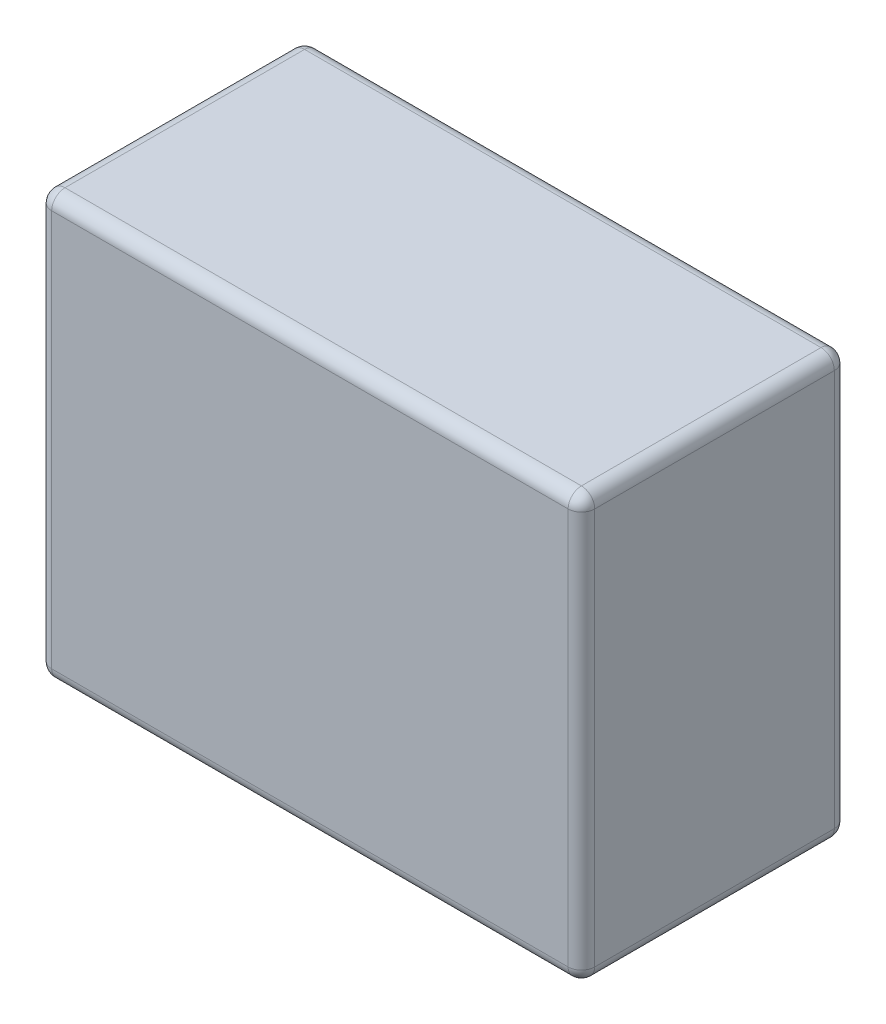
from build123d import *

# Parameters (mm, degrees)
SKETCH1_W           = 40.8
SKETCH1_H           = 20
BOSS_EXTRUDE1_DEPTH = 36.4
SKETCH2_W           = 40.8
SKETCH2_H           = 20
SKETCH2_W_2         = 37.24847256
SKETCH2_H_2         = 17
CUT_EXTRUDE1_DEPTH  = 4.6
SKETCH3_W           = 37.24847256
SKETCH3_H           = 17
SKETCH3_R           = 5
CUT_EXTRUDE2_DEPTH  = 3.9
SKETCH4_R           = 5
SKETCH4_R_2         = 3.5
CUT_EXTRUDE3_DEPTH  = 3
FILLET1_R           = 1
FILLET2_R           = 0.25


with BuildPart() as part:
    # Sketch1 → Boss-Extrude1 (new body)
    with BuildSketch(Plane(origin=(0, 0, 0), x_dir=(1, 0, 0), z_dir=(0, 1, 0))):
        Rectangle(SKETCH1_W, SKETCH1_H)
    extrude(amount=BOSS_EXTRUDE1_DEPTH)

    # Sketch2 → Cut-Extrude1 (cut)
    with BuildSketch(Plane(origin=(0, 0, 0), x_dir=(1, 0, 0), z_dir=(0, 1, 0))):
        Rectangle(SKETCH2_W, SKETCH2_H)
        Rectangle(SKETCH2_W_2, SKETCH2_H_2, mode=Mode.SUBTRACT)
    extrude(amount=CUT_EXTRUDE1_DEPTH, mode=Mode.SUBTRACT)

    # Sketch3 → Cut-Extrude2 (cut)
    with BuildSketch(Plane(origin=(0, 0, 0), x_dir=(1, 0, 0), z_dir=(0, 1, 0))):
        Rectangle(SKETCH3_W, SKETCH3_H)
        with Locations((9.31211814, 0)):
            Circle(SKETCH3_R, mode=Mode.SUBTRACT)
    extrude(amount=CUT_EXTRUDE2_DEPTH, mode=Mode.SUBTRACT)

    # Sketch4 → Cut-Extrude3 (cut)
    with BuildSketch(Plane(origin=(0, 0, 0), x_dir=(1, 0, 0), z_dir=(0, 1, 0))):
        with Locations((9.31211814, 0)):
            Circle(SKETCH4_R)
        with Locations((9.31211814, 0)):
            Circle(SKETCH4_R_2, mode=Mode.SUBTRACT)
    extrude(amount=CUT_EXTRUDE3_DEPTH, mode=Mode.SUBTRACT)

    # Fillet1
    fillet1_edges = [part.edges().sort_by_distance(p)[0] for p in [
        (20.4, 36.4, 0),
        (0, 36.4, -10),
        (-20.4, 4.6, 0),
        (0, 4.6, 10),
        (20.4, 4.6, 0),
        (0, 4.6, -10),
        (-20.4, 36.4, 0),
        (0, 36.4, 10),
        (-20.4, 20.5, -10),
        (20.4, 20.5, -10),
        (20.4, 20.5, 10),
        (-20.4, 20.5, 10),
    ]]
    fillet(fillet1_edges, radius=FILLET1_R)

    # Fillet2
    fillet2_edges = [part.edges().sort_by_distance(p)[0] for p in [
        (-18.62423628, 4.6, 0),
        (0, 4.6, 8.5),
        (18.62423628, 4.6, 0),
        (18.62423628, 4.25, -8.5),
        (0, 4.6, -8.5),
        (-18.62423628, 4.25, -8.5),
        (-18.62423628, 3.9, 0),
        (0, 3.9, 8.5),
        (18.62423628, 3.9, 0),
        (0, 3.9, -8.5),
    ]]
    fillet(fillet2_edges, radius=FILLET2_R)


solid = part.part
